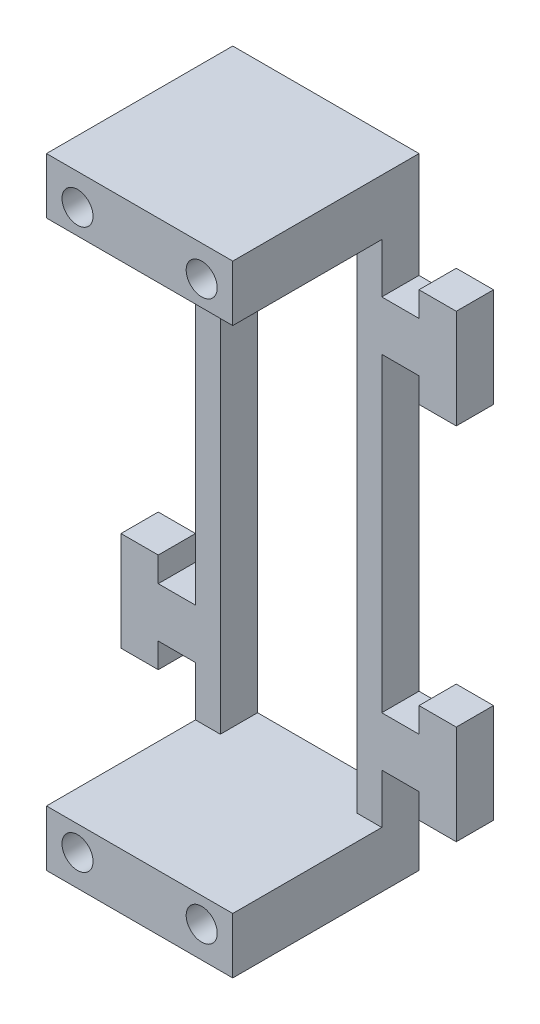
from build123d import *

# Parameters (mm, degrees)
SKETCH_1_W             = 15
SKETCH_1_H             = 50
EXTRUDE_1_DEPTH        = 3
SKETCH_2_W             = 15
SKETCH_2_H             = 4.5
EXTRUDE_2_DEPTH        = 12
SKETCH_3_W             = 15
SKETCH_3_H             = 50
SKETCH_3_W_2           = 11
SKETCH_3_H_2           = 41
EXTRUDE_3_DEPTH        = 3
EXTRUDE_4_DEPTH        = 3
HOLE_WIZARD_M3_1_D     = 2.5
HOLE_WIZARD_M3_1_DEPTH = 3
CUT_EXTRUDE_1_REACH    = 23
SKETCH_8_W             = 3
SKETCH_8_H             = 50
HOLE_WIZARD_M3_2_D     = 2.5
HOLE_WIZARD_M3_2_DEPTH = 10
HOLE_WIZARD_M3_2_TIP   = 0.751075774


with BuildPart() as part:
    # 스케치1 → 보스-돌출1 (new body)
    with BuildSketch(Plane.XY):
        Rectangle(SKETCH_1_W, SKETCH_1_H)
    extrude(amount=EXTRUDE_1_DEPTH)

    # 스케치2 → 보스-돌출2 (add)
    with BuildSketch(Plane(origin=(0, 0, 0), x_dir=(-1, 0, 0), z_dir=(0, 0, -1))):
        with Locations((0, 22.75)):
            Rectangle(SKETCH_2_W, SKETCH_2_H)
        with Locations((0, -22.75)):
            Rectangle(SKETCH_2_W, SKETCH_2_H)
    extrude(amount=EXTRUDE_2_DEPTH)

    # 스케치3 → 보스-돌출3 (add)
    with BuildSketch(Plane(origin=(0, 0, -12), x_dir=(-1, 0, 0), z_dir=(0, 0, -1))):
        Rectangle(SKETCH_3_W, SKETCH_3_H)
        Rectangle(SKETCH_3_W_2, SKETCH_3_H_2, mode=Mode.SUBTRACT)
    extrude(amount=EXTRUDE_3_DEPTH)

    # 스케치5 → 보스-돌출4 (add)
    with BuildSketch(Plane(origin=(0, 0, -15), x_dir=(-1, 0, 0), z_dir=(0, 0, -1))):
        Polygon((-7.5, 16.5), (-10.5, 16.5), (-10.5, 18.5), (-13.5, 18.5), (-13.5, 10.5), (-10.5, 10.5), (-10.5, 12.5), (-7.5, 12.5), align=None)
        Polygon((7.5, 16.5), (7.5, 12.5), (10.5, 12.5), (10.5, 10.5), (13.5, 10.5), (13.5, 18.5), (10.5, 18.5), (10.5, 16.5), align=None)
        Polygon((7.5, -16.5), (10.5, -16.5), (10.5, -18.5), (13.5, -18.5), (13.5, -10.5), (10.5, -10.5), (10.5, -12.5), (7.5, -12.5), align=None)
        Polygon((-7.5, -16.5), (-7.5, -12.5), (-10.5, -12.5), (-10.5, -10.5), (-13.5, -10.5), (-13.5, -18.5), (-10.5, -18.5), (-10.5, -16.5), align=None)
    extrude(amount=-EXTRUDE_4_DEPTH)

    # M3 나사 구멍1
    with Locations(Plane.XY.offset(3)):
        with Locations((0, 5), (0, -5)):
            Hole(HOLE_WIZARD_M3_1_D / 2, depth=HOLE_WIZARD_M3_1_DEPTH)

    # 스케치8 → 컷-돌출1 (cut, up to next)
    with BuildSketch(Plane.ZY.offset(7.5), mode=Mode.PRIVATE) as cut_extrude_1_sk1:
        with Locations((1.5, 0)):
            Rectangle(SKETCH_8_W, SKETCH_8_H)
    cut_extrude_1_tool1 = extrude(cut_extrude_1_sk1.sketch, amount=-CUT_EXTRUDE_1_REACH, mode=Mode.PRIVATE) & part.part
    add(cut_extrude_1_tool1.solids().sort_by_distance((-7.5, 0, 1.5))[0], mode=Mode.SUBTRACT)

    # M3 나사 구멍2
    with Locations(Plane.XY):
        with Locations((-5, 22.5), (5, 22.5), (-5, -22.5), (5, -22.5)):
            Hole(HOLE_WIZARD_M3_2_D / 2, depth=HOLE_WIZARD_M3_2_DEPTH)
            with Locations((0, 0, -(HOLE_WIZARD_M3_2_DEPTH + HOLE_WIZARD_M3_2_TIP / 2))):  # 118° drill point
                Cone(0, HOLE_WIZARD_M3_2_D / 2, HOLE_WIZARD_M3_2_TIP, mode=Mode.SUBTRACT)


solid = part.part
